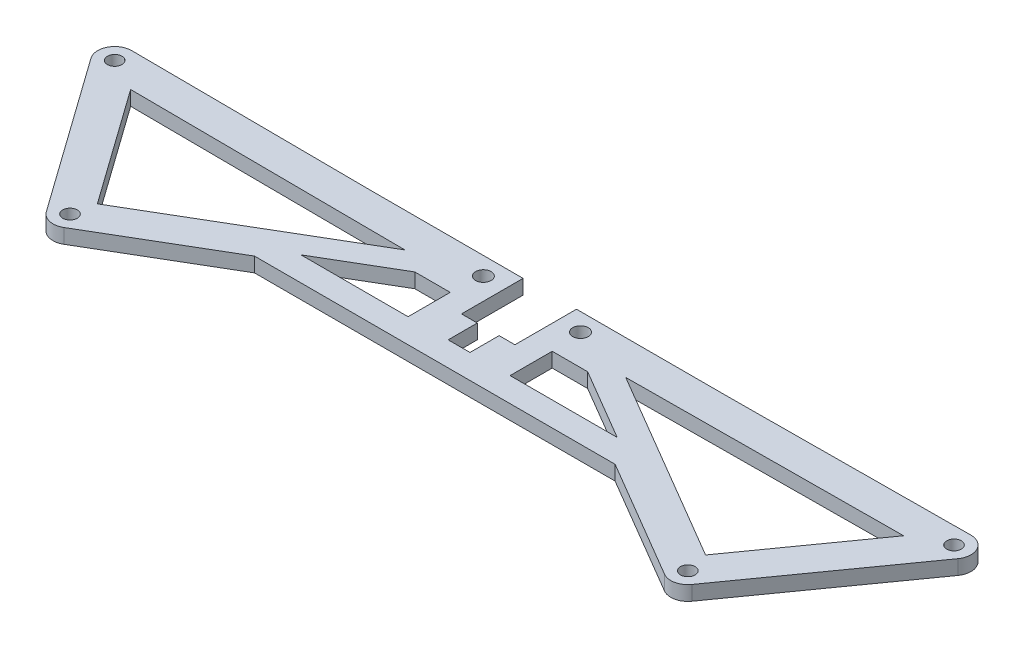
from build123d import *

# Parameters (mm, degrees)
SKETCH_1_W          = 182
SKETCH_1_H          = 40
EXTRUDE_1_DEPTH     = 1.5
SKETCH_2_R          = 1.5
CUT_EXTRUDE_1_DEPTH = 94.220169491
SKETCH_3_R          = 1.6
CUT_EXTRUDE_2_DEPTH = 94.220169491
CUT_EXTRUDE_3_DEPTH = 94.220169491
CUT_EXTRUDE_4_DEPTH = 93.146676554


with BuildPart() as part:
    # 草图1 → 凸台-拉伸1 (new, symmetric)
    with BuildSketch(Plane(origin=(0, 0, 0), x_dir=(1, 0, 0), z_dir=(0, 1, 0))):
        Rectangle(SKETCH_1_W, SKETCH_1_H)
    extrude(amount=EXTRUDE_1_DEPTH, both=True)

    # 草图2 → 切除-拉伸1 (cut, through all)
    with BuildSketch(Plane(origin=(0, 1.5, 0), x_dir=(1, 0, 0), z_dir=(0, 1, 0))):
        with Locations(Location((-86.4, 15.5, 0), (0, 0, 270))):
            Circle(SKETCH_2_R)
        with Locations(Location((-63.6, -16.5, 0), (0, 0, 270))):
            Circle(SKETCH_2_R)
        with Locations(Location((63.6, -16.5, 0), (0, 0, 90))):
            Circle(SKETCH_2_R)
        with Locations(Location((86.4, 15.5, 0), (0, 0, 90))):
            Circle(SKETCH_2_R)
    extrude(amount=-CUT_EXTRUDE_1_DEPTH, mode=Mode.SUBTRACT)

    # 草图3 → 切除-拉伸2 (cut, through all)
    with BuildSketch(Plane(origin=(0, 1.5, 0), x_dir=(1, 0, 0), z_dir=(0, 1, 0))):
        with Locations(Location((-10, 15, 0), (0, 0, 270))):
            Circle(SKETCH_3_R)
        with Locations(Location((10, 15, 0), (0, 0, 90))):
            Circle(SKETCH_3_R)
        Polygon((5.5, 20), (-5.5, 20), (-5.5, 6), (-2.25, 6), (-2.25, 0), (2.25, 0), (2.25, 6), (5.5, 6), align=None)
    extrude(amount=-CUT_EXTRUDE_2_DEPTH, mode=Mode.SUBTRACT)

    # 草图4 → 切除-拉伸3 (cut, through all)
    with BuildSketch(Plane(origin=(0, 1.5, 0), x_dir=(1, 0, 0), z_dir=(0, 1, 0))):
        Polygon((-79.576847618, 11.955270909), (-62.609658275, -11.858328169), (-22.72187982, 11.583183423), align=None)
        with BuildLine():
            ThreePointArc((-89.250472649, 13.469038238), (-89.505875328, 17.113548403), (-86.377094731, 18.999925049))
            Line((-86.377094731, 18.999925049), (-37.123877911, 18.677587243))
            Line((-37.123877911, 18.677587243), (-5.5, 18.677587243))
            Line((-5.5, 18.677587243), (-5.5, 20))
            Line((-5.5, 20), (-91, 20))
            Line((-91, 20), (-91, -20))
            Line((-91, -20), (-63.6, -20))
            ThreePointArc((-63.6, -20), (-65.203376723, -19.611138551), (-66.450472649, -18.530961762))
            Line((-66.450472649, -18.530961762), (-89.250472649, 13.469038238))
        make_face()
        with BuildLine():
            Line((-37.123877911, -5), (-61.826659834, -19.517493108))
            ThreePointArc((-61.826659834, -19.517493108), (-62.68109464, -19.877219705), (-63.6, -20))
            Line((-63.6, -20), (63.600000006, -20))
            ThreePointArc((63.600000006, -20), (62.681094642, -19.877219706), (61.826659834, -19.517493108))
            Line((61.826659834, -19.517493108), (37.123877911, -5))
            Line((37.123877911, -5), (-37.123877911, -5))
        make_face()
        with BuildLine():
            Line((5.5, 20), (5.5, 18.677587243))
            Line((5.5, 18.677587243), (37.123877911, 18.677587243))
            Line((37.123877911, 18.677587243), (86.377094731, 18.999925049))
            ThreePointArc((86.377094731, 18.999925049), (89.505875328, 17.113548403), (89.250472649, 13.469038238))
            Line((89.250472649, 13.469038238), (66.450472649, -18.530961762))
            ThreePointArc((66.450472649, -18.530961762), (65.203376726, -19.61113855), (63.600000006, -20))
            Line((63.600000006, -20), (91, -20))
            Line((91, -20), (91, 20))
            Line((91, 20), (5.5, 20))
        make_face()
        Polygon((79.576847618, 11.955270909), (22.72187982, 11.583183423), (62.609658275, -11.858328169), align=None)
    extrude(amount=-CUT_EXTRUDE_3_DEPTH, mode=Mode.SUBTRACT)

    # 草图5 → 切除-拉伸4 (cut, through all)
    with BuildSketch(Plane(origin=(0, 1.5, 0), x_dir=(1, 0, 0), z_dir=(0, 1, 0))):
        Polygon((-17.797622354, 8.677587243), (-32.563294615, 0), (-10.5, 0), (-10.5, 8.677587243), align=None)
        Polygon((17.797622354, 8.677587243), (10.5, 8.677587243), (10.5, 0), (32.563294615, 0), align=None)
    extrude(amount=-CUT_EXTRUDE_4_DEPTH, mode=Mode.SUBTRACT)


solid = part.part
